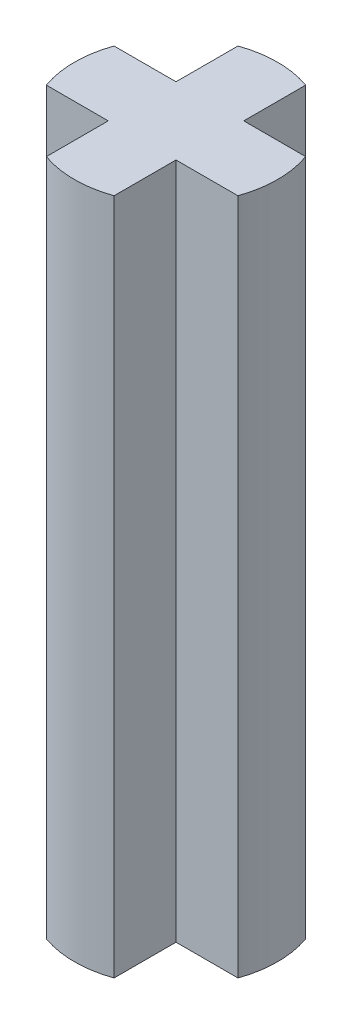
from build123d import *

# Parameters (mm, degrees)
SKETCH1_W           = 3
SKETCH1_H           = 1
SKETCH1_W_2         = 1
SKETCH1_H_2         = 3
BOSS_EXTRUDE1_DEPTH = 10
SKETCH2_OUTSIDE_W   = 7.172
SKETCH2_OUTSIDE_H   = 7.172
SKETCH2_OUTSIDE_R   = 1.5
CUT_EXTRUDE1_DEPTH  = 10


with BuildPart() as part:
    # Sketch1 → Boss-Extrude1 (new body)
    with BuildSketch(Plane(origin=(0, 0, 0), x_dir=(1, 0, 0), z_dir=(0, 1, 0))):
        Rectangle(SKETCH1_W, SKETCH1_H)
        Rectangle(SKETCH1_W_2, SKETCH1_H_2)
    extrude(amount=BOSS_EXTRUDE1_DEPTH)

    # Sketch2 outside → Cut-Extrude1 (cut)
    with BuildSketch(Plane(origin=(0, 10, 0), x_dir=(1, 0, 0), z_dir=(0, 1, 0))):
        Rectangle(SKETCH2_OUTSIDE_W, SKETCH2_OUTSIDE_H)
        Circle(SKETCH2_OUTSIDE_R, mode=Mode.SUBTRACT)
    extrude(amount=-CUT_EXTRUDE1_DEPTH, mode=Mode.SUBTRACT)


solid = part.part
